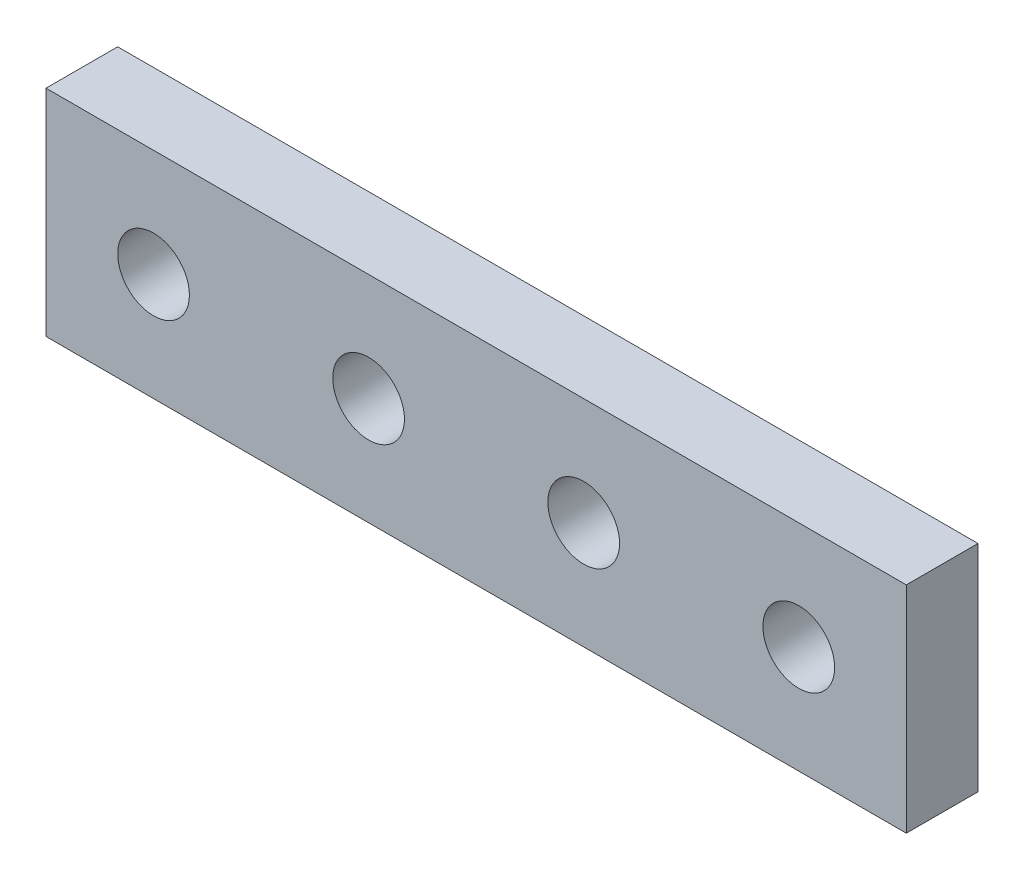
from build123d import *

# Parameters (mm, degrees)
SKETCH1_W           = 120
SKETCH1_H           = 30
SKETCH1_R           = 5
BOSS_EXTRUDE1_DEPTH = 10


with BuildPart() as part:
    # Sketch1 → Boss-Extrude1 (new body)
    with BuildSketch(Plane.XY):
        with Locations((60, 15)):
            Rectangle(SKETCH1_W, SKETCH1_H)
        with Locations((15, 15)):
            Circle(SKETCH1_R, mode=Mode.SUBTRACT)
        with Locations((45, 15)):
            Circle(SKETCH1_R, mode=Mode.SUBTRACT)
        with Locations((75, 15)):
            Circle(SKETCH1_R, mode=Mode.SUBTRACT)
        with Locations((105, 15)):
            Circle(SKETCH1_R, mode=Mode.SUBTRACT)
    extrude(amount=BOSS_EXTRUDE1_DEPTH)


solid = part.part
